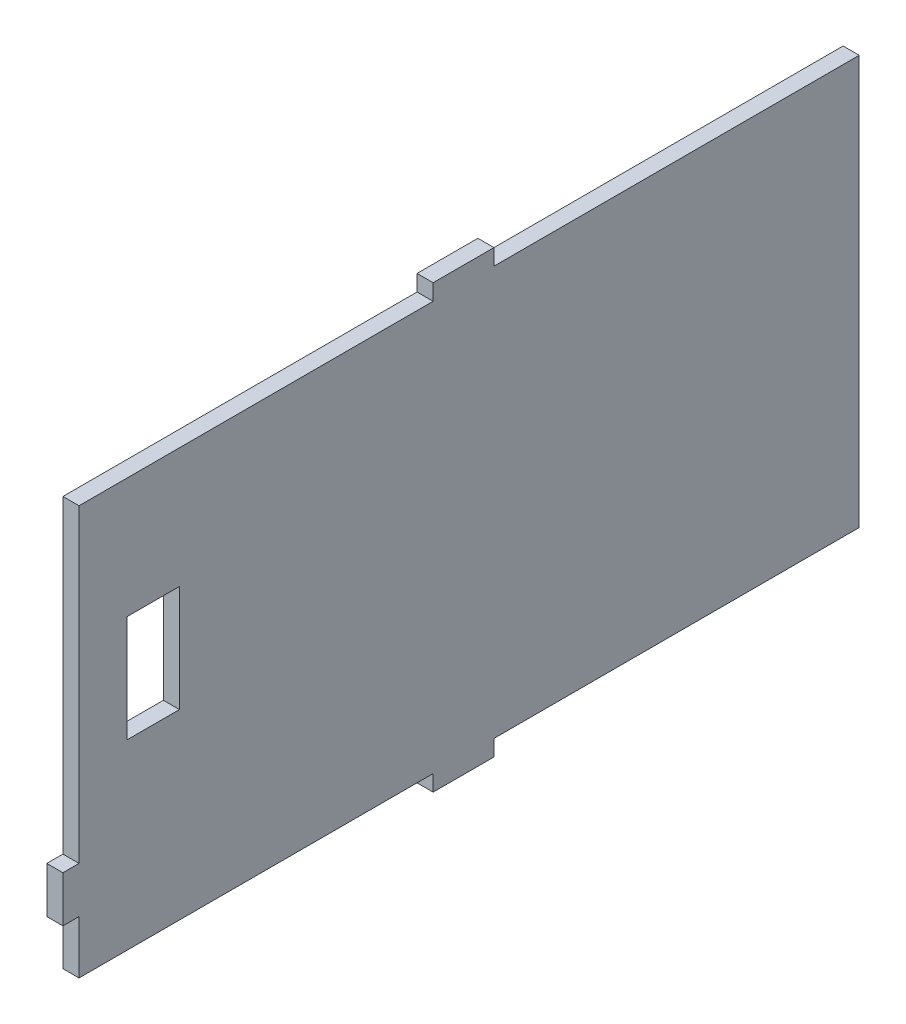
from build123d import *

# Parameters (mm, degrees)
SKETCH1_W           = 38.1
SKETCH1_H           = 40.325
BOSS_EXTRUDE1_DEPTH = 3.175
SKETCH3_W           = 3.175
SKETCH3_H           = 10.49
SKETCH3_H_2         = 20.695
CUT_EXTRUDE2_DEPTH  = 4.175
SKETCH5_W           = 3.175
SKETCH5_H           = 12
BOSS_EXTRUDE2_DEPTH = 3.175
SKETCH7_W           = 3.175
SKETCH7_H           = 80.65
BOSS_EXTRUDE3_DEPTH = 63
SKETCH8_W           = 3.175
SKETCH8_H           = 80.65
BOSS_EXTRUDE4_DEPTH = 55.929385
SKETCH9_W           = 3.175
SKETCH9_H           = 9.082720128
BOSS_EXTRUDE5_DEPTH = 3.18
SKETCH10_W          = 10.316938
SKETCH10_H          = 21.036408148
CUT_EXTRUDE3_DEPTH  = 3.18


with BuildPart() as part:
    # Sketch1 → Boss-Extrude1 (new body)
    with BuildSketch(Plane(origin=(0, 0, 0), x_dir=(0, 0, -1), z_dir=(1, 0, 0))):
        with Locations((-19.05, 20.1625)):
            Rectangle(SKETCH1_W, SKETCH1_H)
    boss_extrude1 = extrude(amount=BOSS_EXTRUDE1_DEPTH)

    # Sketch3 → Cut-Extrude2 (cut, through all)
    with BuildSketch(Plane(origin=(3.175, 0, 0), x_dir=(0, 0, -1), z_dir=(1, 0, 0))):
        with Locations((-36.5125, 35.08)):
            Rectangle(SKETCH3_W, SKETCH3_H)
        with Locations((-36.5125, 10.3475)):
            Rectangle(SKETCH3_W, SKETCH3_H_2)
    cut_extrude2 = extrude(amount=-CUT_EXTRUDE2_DEPTH, mode=Mode.SUBTRACT)

    # Sketch5 → Boss-Extrude2 (add)
    with BuildSketch(Plane(origin=(0, 0, 0), x_dir=(-1, 0, 0), z_dir=(0, -1, 0))):
        with Locations((-1.5875, -15.025)):
            Rectangle(SKETCH5_W, SKETCH5_H)
    boss_extrude2 = extrude(amount=BOSS_EXTRUDE2_DEPTH)

    # Mirror1: Boss-Extrude1, Cut-Extrude2, Boss-Extrude2 across plane
    add(boss_extrude1.mirror(Plane(origin=(3.175, 40.325, 0), x_dir=(0, 0, 1), z_dir=(0, -1, 0))))
    add(cut_extrude2.mirror(Plane(origin=(3.175, 40.325, 0), x_dir=(0, 0, 1), z_dir=(0, -1, 0))), mode=Mode.SUBTRACT)
    add(boss_extrude2.mirror(Plane(origin=(3.175, 40.325, 0), x_dir=(0, 0, 1), z_dir=(0, -1, 0))))

    # Sketch7 → Boss-Extrude3 (add)
    with BuildSketch(Plane(origin=(0, 0, 0), x_dir=(-1, 0, 0), z_dir=(0, 0, -1))):
        with Locations((-1.5875, 40.325)):
            Rectangle(SKETCH7_W, SKETCH7_H)
    extrude(amount=BOSS_EXTRUDE3_DEPTH)

    # Sketch8 → Boss-Extrude4 (add)
    with BuildSketch(Plane.XY.offset(34.925)):
        with Locations((1.5875, 40.325)):
            Rectangle(SKETCH8_W, SKETCH8_H)
    extrude(amount=BOSS_EXTRUDE4_DEPTH)

    # Sketch9 → Boss-Extrude5 (add)
    with BuildSketch(Plane.XY.offset(90.85438473)):
        with Locations((1.5875, 15.031360064)):
            Rectangle(SKETCH9_W, SKETCH9_H)
    extrude(amount=BOSS_EXTRUDE5_DEPTH)

    # Sketch10 → Cut-Extrude3 (cut)
    with BuildSketch(Plane(origin=(3.175, 0, 0), x_dir=(0, 0, -1), z_dir=(1, 0, 0))):
        with Locations((-76.199393077, 46.454229061)):
            Rectangle(SKETCH10_W, SKETCH10_H)
    extrude(amount=-CUT_EXTRUDE3_DEPTH, mode=Mode.SUBTRACT)


solid = part.part
